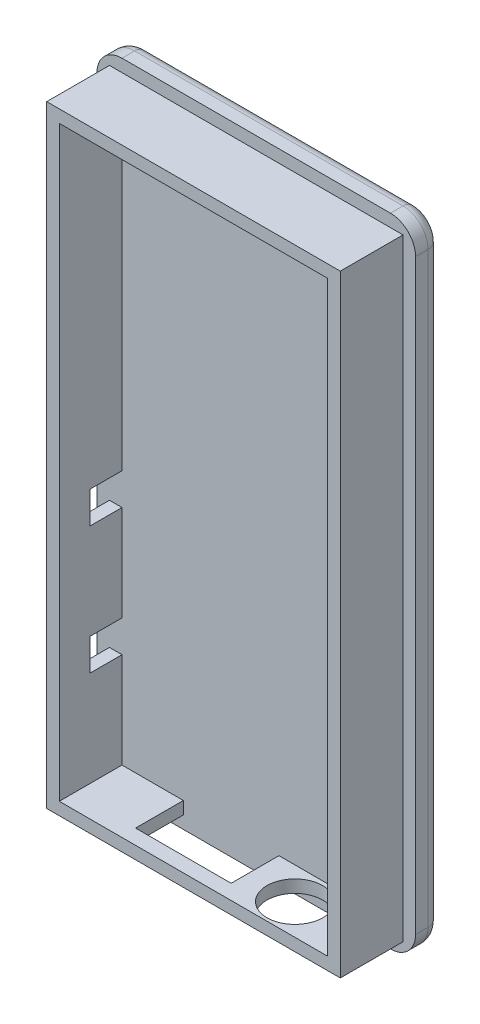
from build123d import *

# Parameters (mm, degrees)
SKETCH2_W           = 25.4
SKETCH2_H           = 50.8
BOSS_EXTRUDE1_DEPTH = 2.00000108
SKETCH3_W           = 23.39999892
SKETCH3_H           = 48.79999892
SKETCH3_W_2         = 21.39999784
SKETCH3_H_2         = 46.79999784
BOSS_EXTRUDE2_DEPTH = 4.999999906
FILLET1_R           = 2.000000064
FILLET2_R           = 1.000000032
CUT_EXTRUDE2_REACH  = 51.8
SKETCH5_R           = 2.2225
CUT_EXTRUDE3_REACH  = 51.8
SKETCH6_W           = 7.62
SKETCH6_H           = 3.81
CUT_EXTRUDE4_REACH  = 26.4
SKETCH7_W           = 2.54
SKETCH7_H           = 2.54


with BuildPart() as part:
    # Sketch2 → Boss-Extrude1 (new body)
    with BuildSketch(Plane.XY):
        with Locations((12.7, 25.4)):
            Rectangle(SKETCH2_W, SKETCH2_H)
    extrude(amount=BOSS_EXTRUDE1_DEPTH)

    # Sketch3 → Boss-Extrude2 (add)
    with BuildSketch(Plane.XY.offset(2.00000108)):
        with Locations((12.7, 25.4)):
            Rectangle(SKETCH3_W, SKETCH3_H)
        with Locations((12.7, 25.4)):
            Rectangle(SKETCH3_W_2, SKETCH3_H_2, mode=Mode.SUBTRACT)
    extrude(amount=BOSS_EXTRUDE2_DEPTH)

    # Fillet1
    fillet1_edges = [part.edges().sort_by_distance(p)[0] for p in [
        (0, 50.8, 1.00000054),
        (25.4, 50.8, 1.00000054),
        (25.4, 0, 1.00000054),
        (0, 0, 1.00000054),
    ]]
    fillet(fillet1_edges, radius=FILLET1_R)

    # Fillet2
    fillet2_edges = [part.edges().sort_by_distance(p)[0] for p in [
        (0, 25.4, 0),
        (12.7, 50.8, 0),
        (25.4, 25.4, 0),
        (12.7, 0, 0),
        (24.814213544, 50.214213544, 0),
        (24.814213544, 0.585786456, 0),
        (0.585786456, 0.585786456, 0),
        (0.585786456, 50.214213544, 0),
    ]]
    fillet(fillet2_edges, radius=FILLET2_R)

    # Sketch5 → Cut-Extrude2 (cut, up to next)
    with BuildSketch(Plane.XZ.offset(-1.00000054), mode=Mode.PRIVATE) as cut_extrude2_sk1:
        with Locations((18.319999936, 4.54000108)):
            Circle(SKETCH5_R)
    cut_extrude2_tool1 = extrude(cut_extrude2_sk1.sketch, amount=-CUT_EXTRUDE2_REACH, mode=Mode.PRIVATE) & part.part
    add(cut_extrude2_tool1.solids().sort_by_distance((18.32, 1.000001, 4.540001))[0], mode=Mode.SUBTRACT)

    # Sketch6 → Cut-Extrude3 (cut, up to next)
    with BuildSketch(Plane.XZ.offset(-1.00000054), mode=Mode.PRIVATE) as cut_extrude3_sk1:
        with Locations((10.699999936, 3.90500108)):
            Rectangle(SKETCH6_W, SKETCH6_H)
    cut_extrude3_tool1 = extrude(cut_extrude3_sk1.sketch, amount=-CUT_EXTRUDE3_REACH, mode=Mode.PRIVATE) & part.part
    add(cut_extrude3_tool1.solids().sort_by_distance((10.7, 1.000001, 3.905001))[0], mode=Mode.SUBTRACT)

    # Sketch7 → Cut-Extrude4 (cut, up to next)
    with BuildSketch(Plane.ZY.offset(-1.00000054), mode=Mode.PRIVATE) as cut_extrude4_sk1:
        with Locations((3.27000108, 10.890000064)):
            Rectangle(SKETCH7_W, SKETCH7_H)
    cut_extrude4_tool1 = extrude(cut_extrude4_sk1.sketch, amount=-CUT_EXTRUDE4_REACH, mode=Mode.PRIVATE) & part.part
    add(cut_extrude4_tool1.solids().sort_by_distance((1.000001, 10.89, 3.270001))[0], mode=Mode.SUBTRACT)
    # Sketch7 → Cut-Extrude4 (cut, up to next)
    with BuildSketch(Plane.ZY.offset(-1.00000054), mode=Mode.PRIVATE) as cut_extrude4_sk2:
        with Locations((3.27000108, 21.050000064)):
            Rectangle(SKETCH7_W, SKETCH7_H)
    cut_extrude4_tool2 = extrude(cut_extrude4_sk2.sketch, amount=-CUT_EXTRUDE4_REACH, mode=Mode.PRIVATE) & part.part
    add(cut_extrude4_tool2.solids().sort_by_distance((1.000001, 21.05, 3.270001))[0], mode=Mode.SUBTRACT)


solid = part.part
